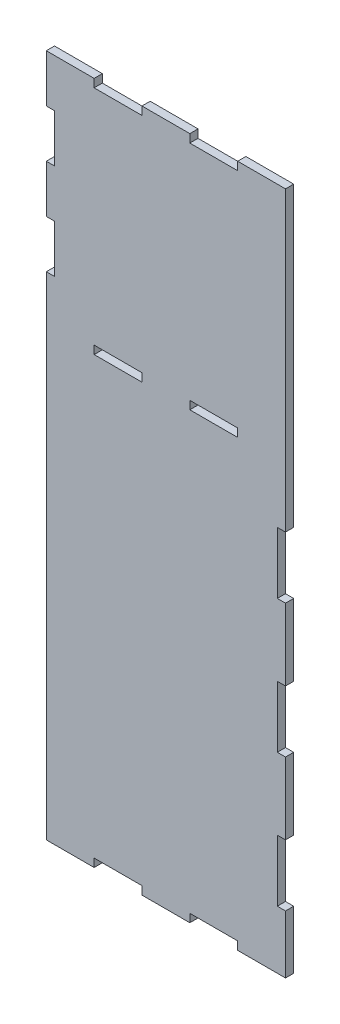
from build123d import *

# Parameters (mm, degrees)
SKETCH1_W           = 70
SKETCH1_H           = 12
BOSS_EXTRUDE2_DEPTH = 12


with BuildPart() as part:
    # Sketch1 → Boss-Extrude2 (new body)
    with BuildSketch(Plane.XY):
        Polygon((280, 1000), (350, 1000), (350, 565), (338, 565), (338, 475), (350, 475), (350, 370), (338, 370), (338, 280), (350, 280), (350, 175), (338, 175), (338, 85), (350, 85), (350, 0), (280, 0), (280, 12), (210, 12), (210, 0), (140, 0), (140, 12), (70, 12), (70, 0), (0, 0), (0, 720), (12, 720), (12, 790), (0, 790), (0, 860), (12, 860), (12, 930), (0, 930), (0, 1000), (70, 1000), (70, 988), (140, 988), (140, 1000), (210, 1000), (210, 988), (280, 988), align=None)
        with Locations((105, 656)):
            Rectangle(SKETCH1_W, SKETCH1_H, mode=Mode.SUBTRACT)
        with Locations((245, 656)):
            Rectangle(SKETCH1_W, SKETCH1_H, mode=Mode.SUBTRACT)
    extrude(amount=BOSS_EXTRUDE2_DEPTH)


solid = part.part
